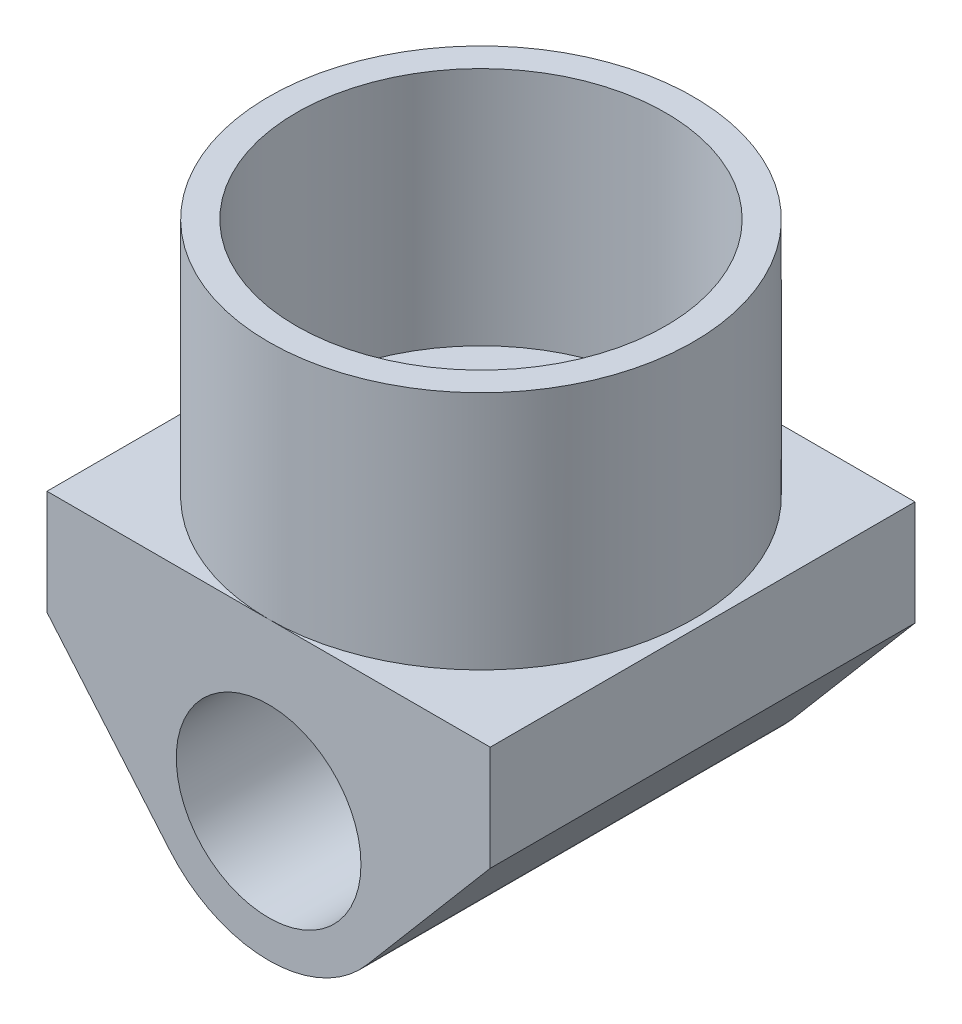
from build123d import *

# Parameters (mm, degrees)
SKETCH1_R               = 29.21
BOSS_EXTRUDE1_DEPTH     = 33.02
SKETCH2_W               = 60.96
SKETCH2_H               = 58.42
BOSS_EXTRUDE2_DEPTH     = 40.64
SKETCH3_R               = 12.7
CUT_EXTRUDE1_DEPTH      = 59.42
SKETCH4_R               = 25.4
CUT_EXTRUDE2_DEPTH      = 33.02
CUT_EXTRUDE3_DEPTH      = 1
CUT_EXTRUDE3_DEPTH_BACK = 59.42


with BuildPart() as part:
    # Sketch1 → Boss-Extrude1 (new body)
    with BuildSketch(Plane(origin=(0, 0, 0), x_dir=(1, 0, 0), z_dir=(0, 1, 0))):
        Circle(SKETCH1_R)
    extrude(amount=BOSS_EXTRUDE1_DEPTH)

    # Sketch2 → Boss-Extrude2 (add)
    with BuildSketch(Plane.XZ):
        Rectangle(SKETCH2_W, SKETCH2_H)
    extrude(amount=BOSS_EXTRUDE2_DEPTH)

    # Sketch3 → Cut-Extrude1 (cut, through all)
    with BuildSketch(Plane.XY.offset(29.21)):
        with Locations((0, -22.86)):
            Circle(SKETCH3_R)
    extrude(amount=-CUT_EXTRUDE1_DEPTH, mode=Mode.SUBTRACT)

    # Sketch4 → Cut-Extrude2 (cut)
    with BuildSketch(Plane(origin=(0, 33.02, 0), x_dir=(1, 0, 0), z_dir=(0, 1, 0))):
        Circle(SKETCH4_R)
    extrude(amount=-CUT_EXTRUDE2_DEPTH, mode=Mode.SUBTRACT)

    # Sketch5 → Cut-Extrude3 (cut, two sides)
    with BuildSketch(Plane.XY.offset(29.21)) as cut_extrude3_sk:
        with BuildLine():
            Line((30.48, -14.429530232), (13.554352704, -34.366864159))
            ThreePointArc((13.554352704, -34.366864159), (7.467809426, -38.995681652), (0, -40.64))
            Line((0, -40.64), (30.48, -40.64))
            Line((30.48, -40.64), (30.48, -14.429530232))
        make_face()
        with BuildLine():
            Line((-30.48, -40.64), (0, -40.64))
            ThreePointArc((0, -40.64), (-7.467809426, -38.995681652), (-13.554352704, -34.366864159))
            Line((-13.554352704, -34.366864159), (-30.48, -14.429530232))
            Line((-30.48, -14.429530232), (-30.48, -40.64))
        make_face()
    extrude(amount=CUT_EXTRUDE3_DEPTH, mode=Mode.SUBTRACT)
    extrude(cut_extrude3_sk.sketch, amount=-CUT_EXTRUDE3_DEPTH_BACK, mode=Mode.SUBTRACT)


solid = part.part
